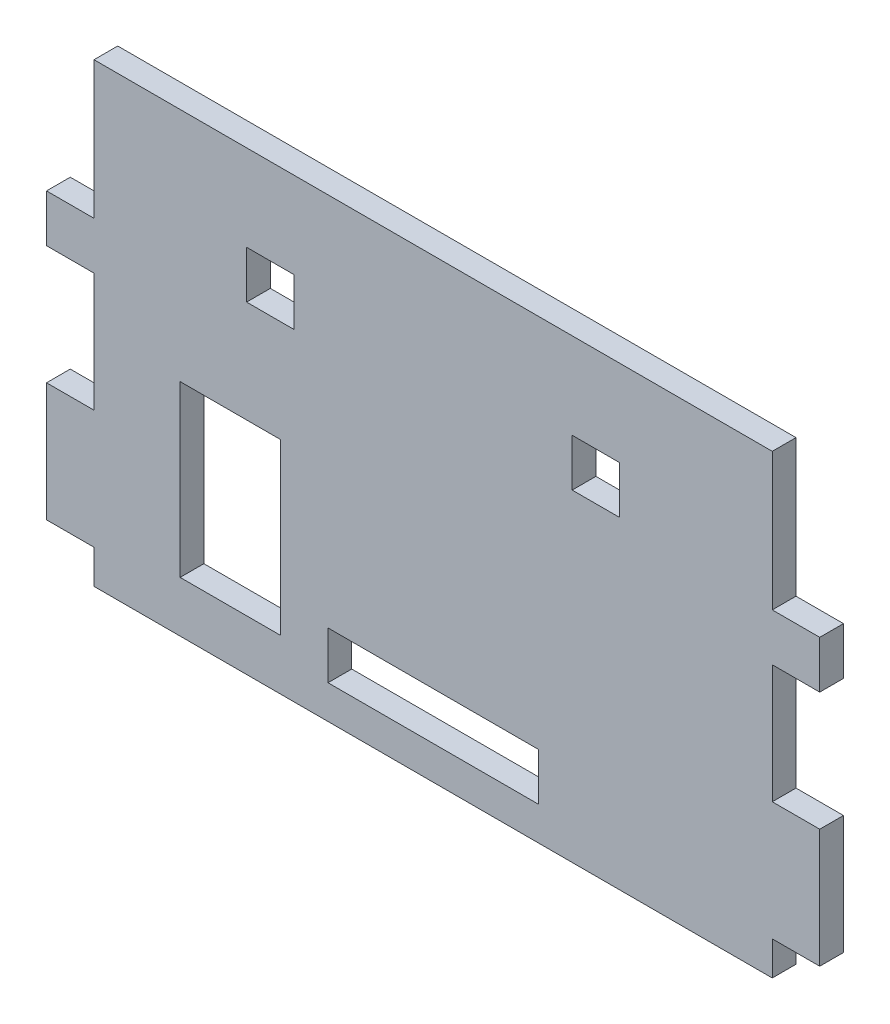
from build123d import *

# Parameters (mm, degrees)
SKETCH1_W           = 14
SKETCH1_H           = 14
SKETCH1_W_2         = 29.6
SKETCH1_H_2         = 50
SKETCH1_W_3         = 62
BOSS_EXTRUDE1_DEPTH = 7


with BuildPart() as part:
    # Sketch1 → Boss-Extrude1 (new body)
    with BuildSketch(Plane.XY):
        Polygon((-200, 45), (-200, 80), (-214, 80), (-214, 94), (-200, 94), (-200, 134.5), (0, 134.5), (0, 94), (14, 94), (14, 80), (0, 80), (0, 45), (14, 45), (14, 10), (0, 10), (0, 0), (-200, 0), (-200, 10), (-214, 10), (-214, 45), align=None)
        with Locations((-148, 102.1)):
            Rectangle(SKETCH1_W, SKETCH1_H, mode=Mode.SUBTRACT)
        with Locations((-52, 102.1)):
            Rectangle(SKETCH1_W, SKETCH1_H, mode=Mode.SUBTRACT)
        with Locations((-159.8, 40)):
            Rectangle(SKETCH1_W_2, SKETCH1_H_2, mode=Mode.SUBTRACT)
        with Locations((-100, 16.9)):
            Rectangle(SKETCH1_W_3, SKETCH1_H, mode=Mode.SUBTRACT)
    extrude(amount=BOSS_EXTRUDE1_DEPTH)


solid = part.part
